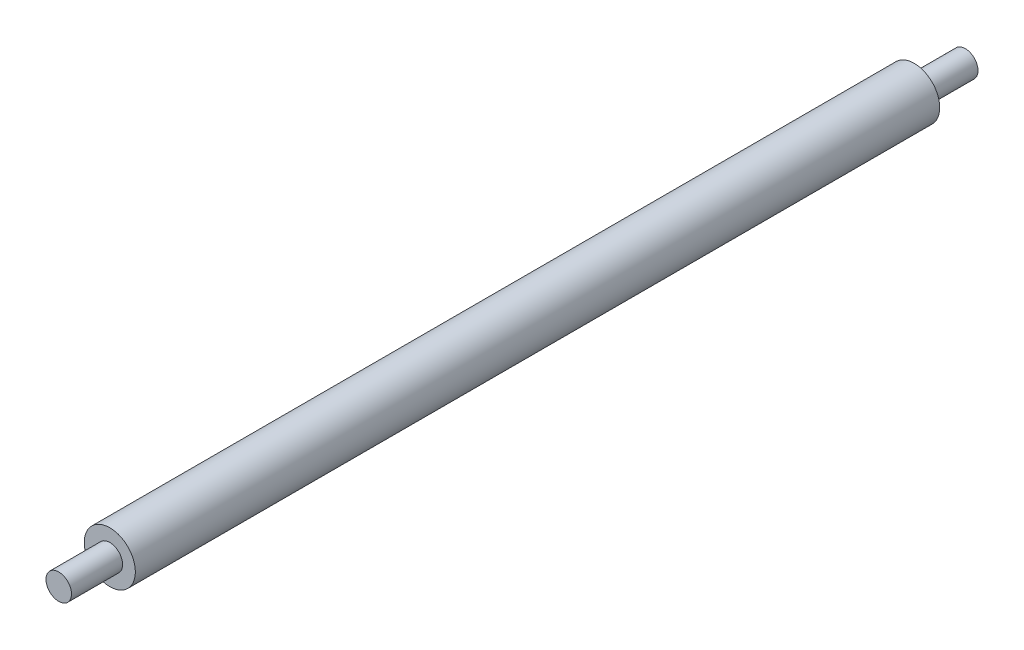
from build123d import *

# Parameters (mm, degrees)
SKETCH1_R           = 10
BOSS_EXTRUDE1_DEPTH = 315
SKETCH2_R           = 5
BOSS_EXTRUDE2_DEPTH = 20
SKETCH3_R           = 5
BOSS_EXTRUDE3_DEPTH = 20


with BuildPart() as part:
    # Sketch1 → Boss-Extrude1 (new body)
    with BuildSketch(Plane.XY):
        Circle(SKETCH1_R)
    extrude(amount=BOSS_EXTRUDE1_DEPTH)

    # Sketch2 → Boss-Extrude2 (add)
    with BuildSketch(Plane.XY.offset(315)):
        Circle(SKETCH2_R)
    extrude(amount=BOSS_EXTRUDE2_DEPTH)

    # Sketch3 → Boss-Extrude3 (add)
    with BuildSketch(Plane(origin=(0, 0, 0), x_dir=(-1, 0, 0), z_dir=(0, 0, -1))):
        Circle(SKETCH3_R)
    extrude(amount=BOSS_EXTRUDE3_DEPTH)


solid = part.part
